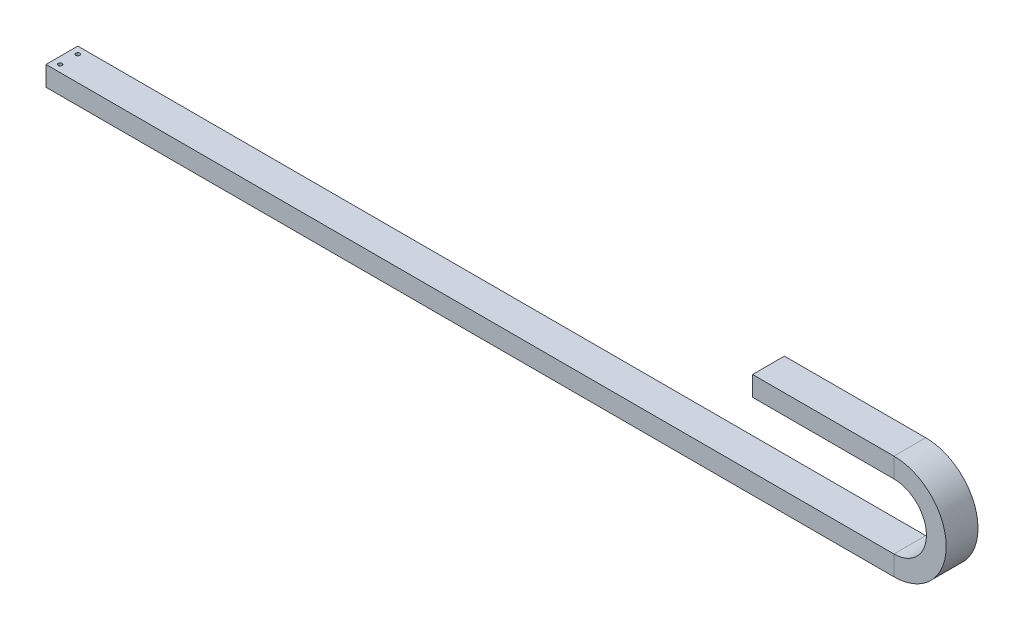
from build123d import *

# Parameters (mm, degrees)
SKETCH_2_W              = 45
SKETCH_2_H              = 28
SKETCH_2_W_2            = 35
SKETCH_2_H_2            = 18
HOLE_WIZARD_5_5_5_5_1_D = 5.5


with BuildPart() as part:
    # 扫描1: sweep along a path in 草图1
    with BuildLine(Plane.XY) as sweep_1_path:
        Line((0, 0), (1200, 0))
        ThreePointArc((1200, 0), (1260, 60), (1200, 120))
        Line((1200, 120), (1000, 120))
    # 草图2 → 扫描1 (sweep)
    with BuildSketch(Plane(origin=(0, 0, 0), x_dir=(0, 0, -1), z_dir=(1, 0, 0))):
        Rectangle(SKETCH_2_W, SKETCH_2_H)
        Rectangle(SKETCH_2_W_2, SKETCH_2_H_2, mode=Mode.SUBTRACT)
    sweep(path=sweep_1_path.line)

    # Ø5.5 (5.5) 直径孔1 (through all)
    with Locations(Plane(origin=(10, 14, -12.5), x_dir=(0, 0, 1), z_dir=(0, 1, 0))):
        with Locations((0, 0), (25, 0)):
            Hole(HOLE_WIZARD_5_5_5_5_1_D / 2)


solid = part.part
